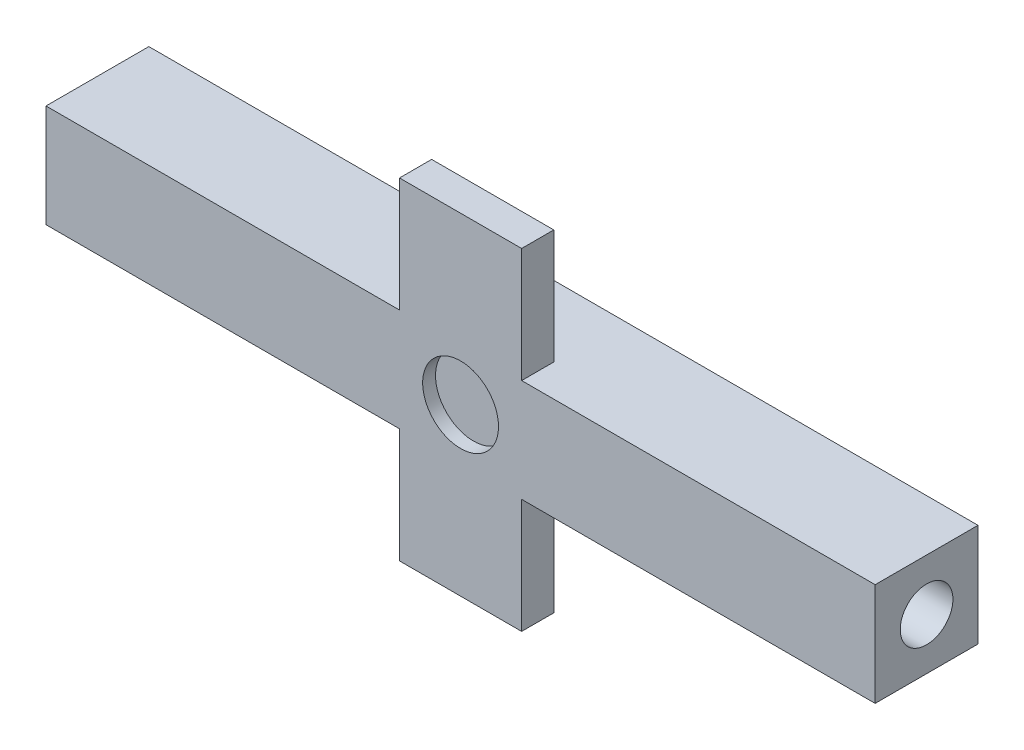
from build123d import *

# Parameters (mm, degrees)
SKETCH1_W           = 10.16
SKETCH1_H           = 10.16
BOSS_EXTRUDE1_DEPTH = 81.915
SKETCH10_R          = 2.6035
CUT_EXTRUDE6_DEPTH  = 82.915
SKETCH11_R          = 3.7465
CUT_EXTRUDE7_DEPTH  = 1.27
SKETCH12_W          = 12.065
SKETCH12_H          = 3.175
BOSS_EXTRUDE4_DEPTH = 11.303
SKETCH13_W          = 12.065
SKETCH13_H          = 3.175
BOSS_EXTRUDE5_DEPTH = 11.303


with BuildPart() as part:
    # Sketch1 → Boss-Extrude1 (new body)
    with BuildSketch(Plane(origin=(0, 0, 0), x_dir=(0, 0, -1), z_dir=(1, 0, 0))):
        with Locations((5.08, 5.08)):
            Rectangle(SKETCH1_W, SKETCH1_H)
    extrude(amount=BOSS_EXTRUDE1_DEPTH)

    # Sketch10 → Cut-Extrude6 (cut, through all)
    with BuildSketch(Plane(origin=(81.915, 0, 0), x_dir=(0, 0, -1), z_dir=(1, 0, 0))):
        with Locations((5.08, 5.08)):
            Circle(SKETCH10_R)
    extrude(amount=-CUT_EXTRUDE6_DEPTH, mode=Mode.SUBTRACT)

    # Sketch11 → Cut-Extrude7 (cut)
    with BuildSketch(Plane.XY):
        with Locations((40.9575, 5.08)):
            Circle(SKETCH11_R)
    extrude(amount=-CUT_EXTRUDE7_DEPTH, mode=Mode.SUBTRACT)

    # Sketch12 → Boss-Extrude4 (add)
    with BuildSketch(Plane.XZ):
        with Locations((40.9575, -1.5875)):
            Rectangle(SKETCH12_W, SKETCH12_H)
    extrude(amount=BOSS_EXTRUDE4_DEPTH)

    # Sketch13 → Boss-Extrude5 (add)
    with BuildSketch(Plane(origin=(0, 10.16, 0), x_dir=(1, 0, 0), z_dir=(0, 1, 0))):
        with Locations((40.9575, 1.5875)):
            Rectangle(SKETCH13_W, SKETCH13_H)
    extrude(amount=BOSS_EXTRUDE5_DEPTH)


solid = part.part
